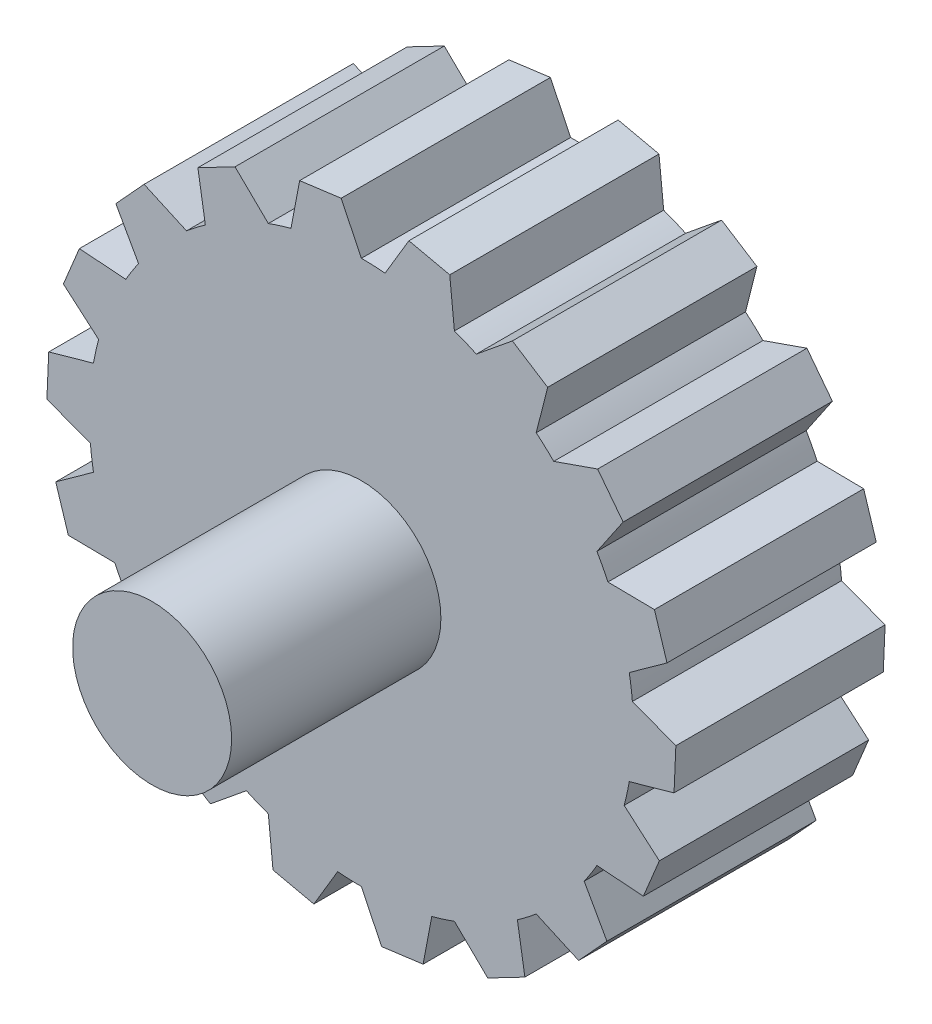
from build123d import *

# Parameters (mm, degrees)
SKETCH2_R           = 1.9
BOSS_EXTRUDE1_DEPTH = 10
SKETCH2_3_R         = 6.5
BOSS_EXTRUDE2_DEPTH = 5
BOSS_EXTRUDE3_DEPTH = 5


with BuildPart() as part:
    # Sketch2 → Boss-Extrude1 (new body)
    with BuildSketch(Plane.XY):
        Circle(SKETCH2_R)
    extrude(amount=BOSS_EXTRUDE1_DEPTH)

    # Sketch2_3 → Boss-Extrude2 (add)
    with BuildSketch(Plane.XY):
        Circle(SKETCH2_3_R)
    extrude(amount=BOSS_EXTRUDE2_DEPTH)

    # Sketch3 → Boss-Extrude3 (add)
    with BuildSketch(Plane(origin=(0, 0, 0), x_dir=(-1, 0, 0), z_dir=(0, 0, -1))):
        with BuildLine():
            Line((0.483224011, 7.501099556), (1.474668872, 7.370573364))
            Line((1.474668872, 7.370573364), (1.682323793, 6.278517871))
            ThreePointArc((1.682323793, 6.278517871), (0.848420249, 6.444391599), (0, 6.5))
            Line((0, 6.5), (0.483224011, 7.501099556))
        make_face()
        with BuildLine():
            Line((3.019609183, 6.883455555), (2.223130932, 6.108002035))
            ThreePointArc((2.223130932, 6.108002035), (3.001365986, 5.765570416), (3.728246836, 5.324488288))
            Line((3.728246836, 5.324488288), (3.906620016, 6.421706942))
            Line((3.906620016, 6.421706942), (3.019609183, 6.883455555))
        make_face()
        with BuildLine():
            Line((5.191784922, 5.435565226), (4.178119463, 4.97928888))
            ThreePointArc((4.178119463, 4.97928888), (4.792302689, 4.39133635), (5.324488288, 3.728246836))
            Line((5.324488288, 3.728246836), (5.86737513, 4.698287889))
            Line((5.86737513, 4.698287889), (5.191784922, 5.435565226))
        make_face()
        with BuildLine():
            Line((6.737754778, 3.332065509), (5.629165125, 3.25))
            ThreePointArc((5.629165125, 3.25), (6.005216961, 2.48744231), (6.278517871, 1.682323793))
            Line((6.278517871, 1.682323793), (7.12043821, 2.408185976))
            Line((7.12043821, 2.408185976), (6.737754778, 3.332065509))
        make_face()
        with BuildLine():
            Line((7.471051968, 0.826669516), (6.401250395, 1.128713155))
            ThreePointArc((6.401250395, 1.128713155), (6.49381344, 0.283526018), (6.475265538, -0.566512328))
            Line((6.475265538, -0.566512328), (7.514671356, -0.172378706))
            Line((7.514671356, -0.172378706), (7.471051968, 0.826669516))
        make_face()
        with BuildLine():
            Line((7.30323003, -1.778435021), (6.401250395, -1.128713155))
            ThreePointArc((6.401250395, -1.128713155), (6.19916018, -1.954587697), (5.891000616, -2.747018701))
            Line((5.891000616, -2.747018701), (7.002524231, -2.732151972))
            Line((7.002524231, -2.732151972), (7.30323003, -1.778435021))
        make_face()
        with BuildLine():
            Line((6.254530767, -4.169034047), (5.629165125, -3.25))
            ThreePointArc((5.629165125, -3.25), (5.156796712, -3.956949289), (4.596194078, -4.596194078))
            Line((4.596194078, -4.596194078), (5.645769338, -4.962387388))
            Line((5.645769338, -4.962387388), (6.254530767, -4.169034047))
        make_face()
        with BuildLine():
            Line((4.451442786, -6.056786039), (4.178119463, -4.97928888))
            ThreePointArc((4.178119463, -4.97928888), (3.492447454, -5.482044398), (2.747018701, -5.891000616))
            Line((2.747018701, -5.891000616), (3.60805134, -6.594085648))
            Line((3.60805134, -6.594085648), (4.451442786, -6.056786039))
        make_face()
        with BuildLine():
            Line((2.111445108, -7.214000246), (2.223130932, -6.108002035))
            ThreePointArc((2.223130932, -6.108002035), (1.406857491, -6.345924046), (0.566512328, -6.475265538))
            Line((0.566512328, -6.475265538), (1.135149101, -7.43043986))
            Line((1.135149101, -7.43043986), (2.111445108, -7.214000246))
        make_face()
        with BuildLine():
            Line((-0.483224011, -7.501099556), (0, -6.5))
            ThreePointArc((0, -6.5), (-0.848420249, -6.444391599), (-1.682323793, -6.278517871))
            Line((-1.682323793, -6.278517871), (-1.474668872, -7.370573364))
            Line((-1.474668872, -7.370573364), (-0.483224011, -7.501099556))
        make_face()
        with BuildLine():
            Line((-3.019609183, -6.883455555), (-2.223130932, -6.108002035))
            ThreePointArc((-2.223130932, -6.108002035), (-3.001365986, -5.765570416), (-3.728246836, -5.324488288))
            Line((-3.728246836, -5.324488288), (-3.906620016, -6.421706942))
            Line((-3.906620016, -6.421706942), (-3.019609183, -6.883455555))
        make_face()
        with BuildLine():
            Line((-5.191784922, -5.435565226), (-4.178119463, -4.97928888))
            ThreePointArc((-4.178119463, -4.97928888), (-4.792302689, -4.39133635), (-5.324488288, -3.728246836))
            Line((-5.324488288, -3.728246836), (-5.86737513, -4.698287889))
            Line((-5.86737513, -4.698287889), (-5.191784922, -5.435565226))
        make_face()
        with BuildLine():
            Line((-6.737754778, -3.332065509), (-5.629165125, -3.25))
            ThreePointArc((-5.629165125, -3.25), (-6.005216961, -2.48744231), (-6.278517871, -1.682323793))
            Line((-6.278517871, -1.682323793), (-7.12043821, -2.408185976))
            Line((-7.12043821, -2.408185976), (-6.737754778, -3.332065509))
        make_face()
        with BuildLine():
            Line((-7.471051968, -0.826669516), (-6.401250395, -1.128713155))
            ThreePointArc((-6.401250395, -1.128713155), (-6.49381344, -0.283526018), (-6.475265538, 0.566512328))
            Line((-6.475265538, 0.566512328), (-7.514671356, 0.172378706))
            Line((-7.514671356, 0.172378706), (-7.471051968, -0.826669516))
        make_face()
        with BuildLine():
            Line((-7.30323003, 1.778435021), (-6.401250395, 1.128713155))
            ThreePointArc((-6.401250395, 1.128713155), (-6.19916018, 1.954587697), (-5.891000616, 2.747018701))
            Line((-5.891000616, 2.747018701), (-7.002524231, 2.732151972))
            Line((-7.002524231, 2.732151972), (-7.30323003, 1.778435021))
        make_face()
        with BuildLine():
            Line((-6.254530767, 4.169034047), (-5.629165125, 3.25))
            ThreePointArc((-5.629165125, 3.25), (-5.156796712, 3.956949289), (-4.596194078, 4.596194078))
            Line((-4.596194078, 4.596194078), (-5.645769338, 4.962387388))
            Line((-5.645769338, 4.962387388), (-6.254530767, 4.169034047))
        make_face()
        with BuildLine():
            Line((-4.451442786, 6.056786039), (-4.178119463, 4.97928888))
            ThreePointArc((-4.178119463, 4.97928888), (-3.492447454, 5.482044398), (-2.747018701, 5.891000616))
            Line((-2.747018701, 5.891000616), (-3.60805134, 6.594085648))
            Line((-3.60805134, 6.594085648), (-4.451442786, 6.056786039))
        make_face()
        with BuildLine():
            Line((-2.111445108, 7.214000246), (-2.223130932, 6.108002035))
            ThreePointArc((-2.223130932, 6.108002035), (-1.406857491, 6.345924046), (-0.566512328, 6.475265538))
            Line((-0.566512328, 6.475265538), (-1.135149101, 7.43043986))
            Line((-1.135149101, 7.43043986), (-2.111445108, 7.214000246))
        make_face()
    extrude(amount=-BOSS_EXTRUDE3_DEPTH)


solid = part.part
